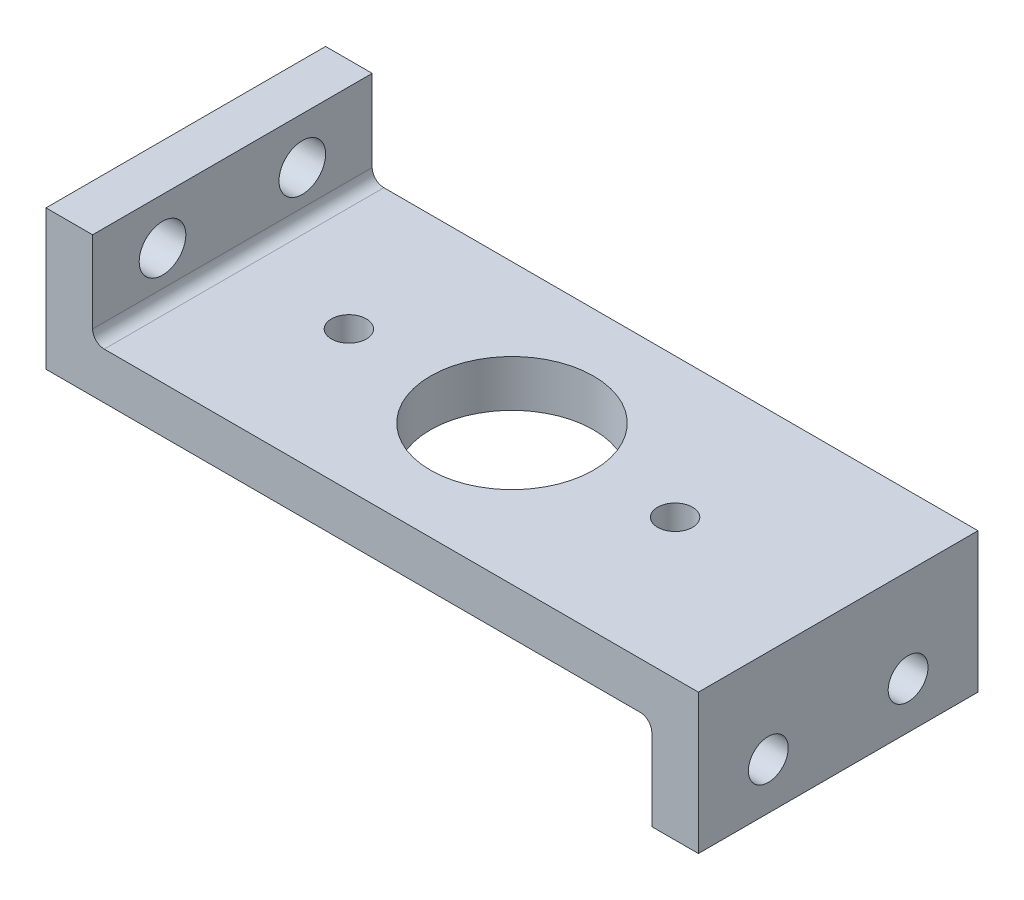
from build123d import *

# Parameters (mm, degrees)
BOSS_EXTRUDE1_DEPTH     = 76.2
SKETCH2_R               = 22.225
SKETCH2_R_2             = 4.7625
CUT_EXTRUDE2_DEPTH      = 34.20727615
CUT_EXTRUDE2_DEPTH_BACK = 31.29272385
CUT_EXTRUDE3_REACH      = 179.8
SKETCH3_R               = 6.35
SKETCH5_R               = 5.428392571
CUT_EXTRUDE4_DEPTH      = 76.2


with BuildPart() as part:
    # Sketch1 → Boss-Extrude1 (new body)
    with BuildSketch(Plane.XY):
        with BuildLine():
            Line((-88.9, -4.89272385), (73.025, -4.89272385))
            ThreePointArc((73.025, -4.89272385), (75.27006403, -5.82265982), (76.2, -8.06772385))
            Line((76.2, -8.06772385), (76.2, -30.29272385))
            Line((76.2, -30.29272385), (88.9, -30.29272385))
            Line((88.9, -30.29272385), (88.9, -4.89272385))
            Line((88.9, -4.89272385), (88.9, 7.80727615))
            Line((88.9, 7.80727615), (-73.025, 7.80727615))
            ThreePointArc((-73.025, 7.80727615), (-75.27006403, 8.73721212), (-76.2, 10.98227615))
            Line((-76.2, 10.98227615), (-76.2, 33.20727615))
            Line((-76.2, 33.20727615), (-88.9, 33.20727615))
            Line((-88.9, 33.20727615), (-88.9, 4.89272385))
            Line((-88.9, 4.89272385), (-88.9, -4.89272385))
        make_face()
    extrude(amount=BOSS_EXTRUDE1_DEPTH)

    # Sketch2 → Cut-Extrude2 (cut, two sides)
    with BuildSketch(Plane(origin=(0, 0, 0), x_dir=(1, 0, 0), z_dir=(0, 1, 0))) as cut_extrude2_sk:
        with Locations((0, -38.1)):
            Circle(SKETCH2_R)
        with Locations((-44.45, -38.1)):
            Circle(SKETCH2_R_2)
        with Locations((44.45, -38.1)):
            Circle(SKETCH2_R_2)
    extrude(amount=CUT_EXTRUDE2_DEPTH, mode=Mode.SUBTRACT)
    extrude(cut_extrude2_sk.sketch, amount=-CUT_EXTRUDE2_DEPTH_BACK, mode=Mode.SUBTRACT)

    # Sketch3 → Cut-Extrude3 (cut, up to next)
    with BuildSketch(Plane.ZY.offset(88.9), mode=Mode.PRIVATE) as cut_extrude3_sk1:
        with Locations((19.05, 20.50727615)):
            Circle(SKETCH3_R)
    cut_extrude3_tool1 = extrude(cut_extrude3_sk1.sketch, amount=-CUT_EXTRUDE3_REACH, mode=Mode.PRIVATE) & part.part
    add(cut_extrude3_tool1.solids().sort_by_distance((-88.9, 20.507276, 19.05))[0], mode=Mode.SUBTRACT)
    # Sketch3 → Cut-Extrude3 (cut, up to next)
    with BuildSketch(Plane.ZY.offset(88.9), mode=Mode.PRIVATE) as cut_extrude3_sk2:
        with Locations((57.15, 20.50727615)):
            Circle(SKETCH3_R)
    cut_extrude3_tool2 = extrude(cut_extrude3_sk2.sketch, amount=-CUT_EXTRUDE3_REACH, mode=Mode.PRIVATE) & part.part
    add(cut_extrude3_tool2.solids().sort_by_distance((-88.9, 20.507276, 57.15))[0], mode=Mode.SUBTRACT)

    # Sketch5 → Cut-Extrude4 (cut)
    with BuildSketch(Plane(origin=(88.9, 0, 0), x_dir=(0, 0, -1), z_dir=(1, 0, 0))):
        with Locations((-57.15, -17.59272385)):
            Circle(SKETCH5_R)
        with Locations((-19.05, -17.59272385)):
            Circle(SKETCH5_R)
    extrude(amount=-CUT_EXTRUDE4_DEPTH, mode=Mode.SUBTRACT)


solid = part.part
